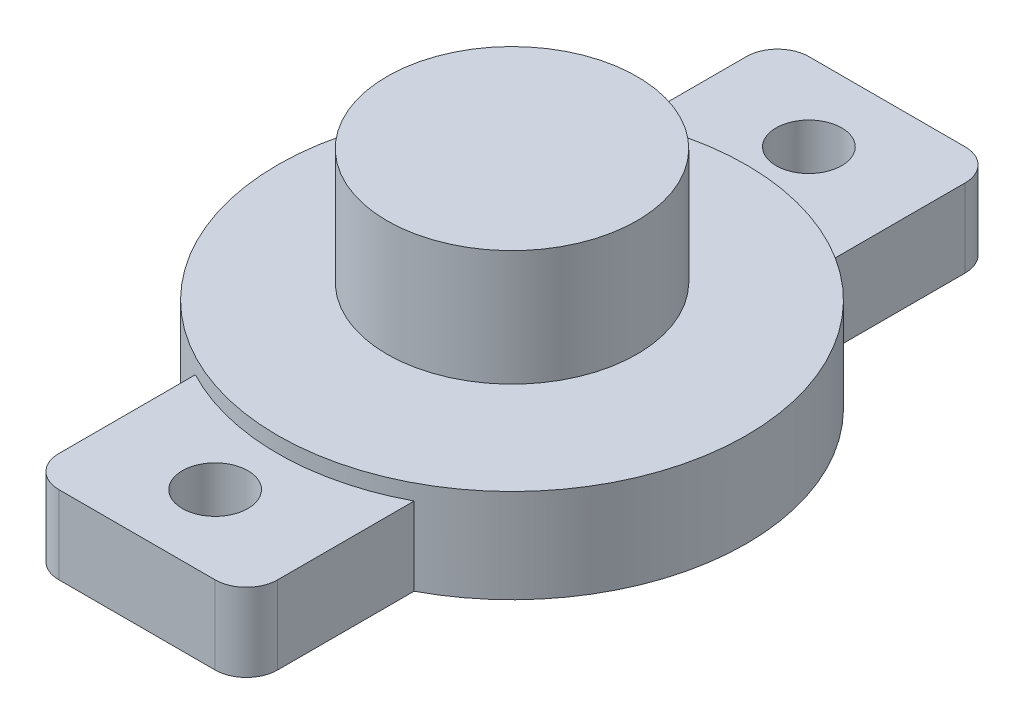
from build123d import *

# Parameters (mm, degrees)
SKETCH1_W                = 7
SKETCH1_H                = 24
BOSS_EXTRUDE1_DEPTH      = 2.5
FILLET1_R                = 1
SKETCH2_R                = 7.5
BOSS_EXTRUDE2_DEPTH      = 0.5
BOSS_EXTRUDE2_DEPTH_BACK = 2.5
SKETCH3_R                = 1.05
CUT_EXTRUDE1_DEPTH       = 22.5
SKETCH5_R                = 1.561205439
BOSS_EXTRUDE3_DEPTH      = 0.5
SKETCH6_R                = 4
BOSS_EXTRUDE4_DEPTH      = 3.7


with BuildPart() as part:
    # Sketch1 → Boss-Extrude1 (new body)
    with BuildSketch(Plane(origin=(0, 0, 0), x_dir=(1, 0, 0), z_dir=(0, 1, 0))):
        Rectangle(SKETCH1_W, SKETCH1_H)
    extrude(amount=BOSS_EXTRUDE1_DEPTH)

    # Fillet1
    fillet1_edges = [part.edges().sort_by_distance(p)[0] for p in [
        (3.5, 1.25, 12),
        (-3.5, 1.25, 12),
        (-3.5, 1.25, -12),
        (3.5, 1.25, -12),
    ]]
    fillet(fillet1_edges, radius=FILLET1_R)

    # Sketch2 → Boss-Extrude2 (add, two sides)
    with BuildSketch(Plane(origin=(0, 2.5, 0), x_dir=(1, 0, 0), z_dir=(0, 1, 0))) as boss_extrude2_sk:
        Circle(SKETCH2_R)
    extrude(amount=BOSS_EXTRUDE2_DEPTH)
    extrude(boss_extrude2_sk.sketch, amount=-BOSS_EXTRUDE2_DEPTH_BACK)

    # Sketch3 → Cut-Extrude1 (cut)
    with BuildSketch(Plane(origin=(0, 2.5, 0), x_dir=(1, 0, 0), z_dir=(0, 1, 0))):
        with Locations((0, 9.5)):
            Circle(SKETCH3_R)
        with Locations((0, -9.5)):
            Circle(SKETCH3_R)
    extrude(amount=-CUT_EXTRUDE1_DEPTH, mode=Mode.SUBTRACT)

    # Sketch5 → Boss-Extrude3 (add)
    with BuildSketch(Plane(origin=(0, 3, 0), x_dir=(1, 0, 0), z_dir=(0, 1, 0))):
        Circle(SKETCH5_R)
    extrude(amount=BOSS_EXTRUDE3_DEPTH)

    # Sketch6 → Boss-Extrude4 (add)
    with BuildSketch(Plane(origin=(0, 3.5, 0), x_dir=(1, 0, 0), z_dir=(0, 1, 0))):
        Circle(SKETCH6_R)
    extrude(amount=BOSS_EXTRUDE4_DEPTH)


solid = part.part
